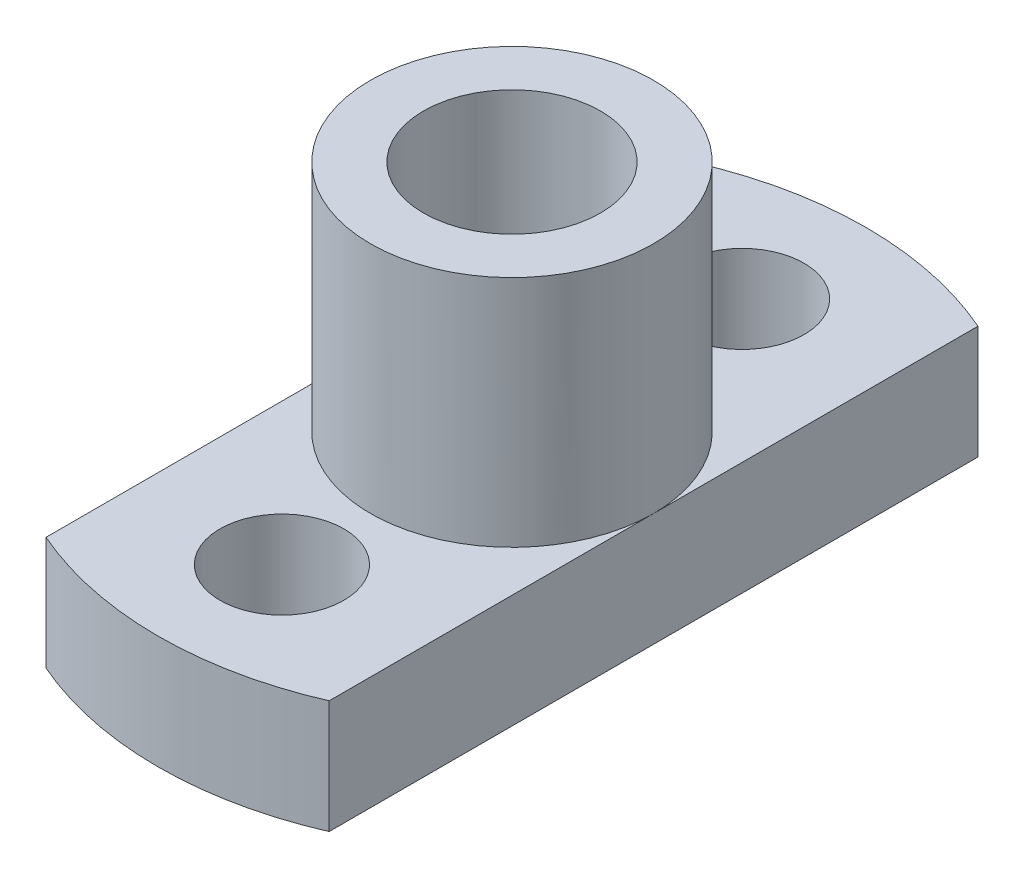
from build123d import *

# Parameters (mm, degrees)
SKETCH_2_R          = 1.75
EXTRUDE_1_DEPTH     = 3.2
SKETCH_3_R          = 4
EXTRUDE_2_DEPTH     = 6.6
SKETCH_4_R          = 2.5
CUT_EXTRUDE_1_DEPTH = 10.8


with BuildPart() as part:
    # 草图2 → 凸台-拉伸1 (new body)
    with BuildSketch(Plane(origin=(0, 0, 0), x_dir=(1, 0, 0), z_dir=(0, 1, 0))):
        with BuildLine():
            Line((-4, 9.16515139), (-4, -9.16515139))
            ThreePointArc((-4, -9.16515139), (0, -10), (4, -9.16515139))
            Line((4, -9.16515139), (4, 9.16515139))
            ThreePointArc((4, 9.16515139), (0, 10), (-4, 9.16515139))
        make_face()
        with Locations((0, 6.5)):
            Circle(SKETCH_2_R, mode=Mode.SUBTRACT)
        with Locations((0, -6.5)):
            Circle(SKETCH_2_R, mode=Mode.SUBTRACT)
    extrude(amount=EXTRUDE_1_DEPTH)

    # 草图3 → 凸台-拉伸2 (add)
    with BuildSketch(Plane(origin=(0, 3.2, 0), x_dir=(1, 0, 0), z_dir=(0, 1, 0))):
        Circle(SKETCH_3_R)
    extrude(amount=EXTRUDE_2_DEPTH)

    # 草图4 → 切除-拉伸1 (cut, through all)
    with BuildSketch(Plane(origin=(0, 9.8, 0), x_dir=(1, 0, 0), z_dir=(0, 1, 0))):
        Circle(SKETCH_4_R)
    extrude(amount=-CUT_EXTRUDE_1_DEPTH, mode=Mode.SUBTRACT)


solid = part.part
